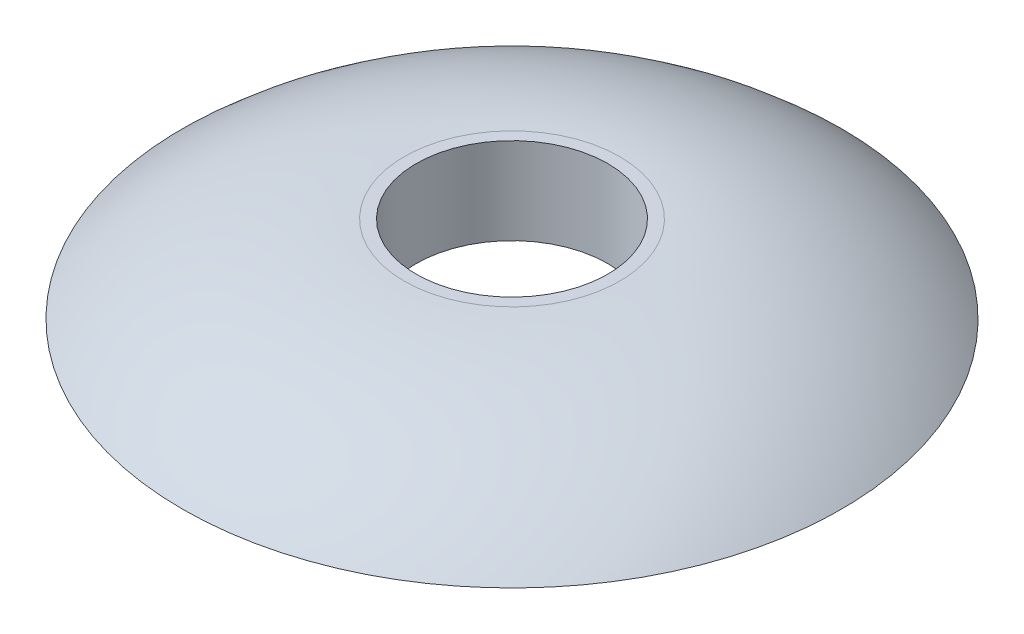
from build123d import *

# Parameters (mm, degrees)
FILLET1_R = 2.54


with BuildPart() as part:
    # Sketch1 → Revolve1 (revolve)
    with BuildSketch(Plane.XY):
        with BuildLine():
            Line((-12.7, 0), (-12.7, 11.478846154))
            Line((-12.7, 11.478846154), (-14.2875, 11.478846154))
            ThreePointArc((-14.2875, 11.478846154), (-30.060922467, 8.507285925), (-43.671841345, 0))
            Line((-43.671841345, 0), (-41.275, 0))
            ThreePointArc((-41.275, 0), (-28.659033364, 7.340612874), (-14.2875, 9.891346154))
            Line((-14.2875, 9.891346154), (-14.2875, 1.953846154))
            Line((-14.2875, 1.953846154), (-37.733653846, 1.953846154))
            Line((-37.733653846, 1.953846154), (-39.6875, 0))
            Line((-39.6875, 0), (-12.7, 0))
        make_face()
    revolve(axis=Axis((0, 0, 0), (0, 1, 0)))

    # Fillet1
    fillet1_edges = [part.edges().sort_by_distance(p)[0] for p in [
        (14.2875, 1.953846154, 0),
    ]]
    fillet(fillet1_edges, radius=FILLET1_R)


solid = part.part
